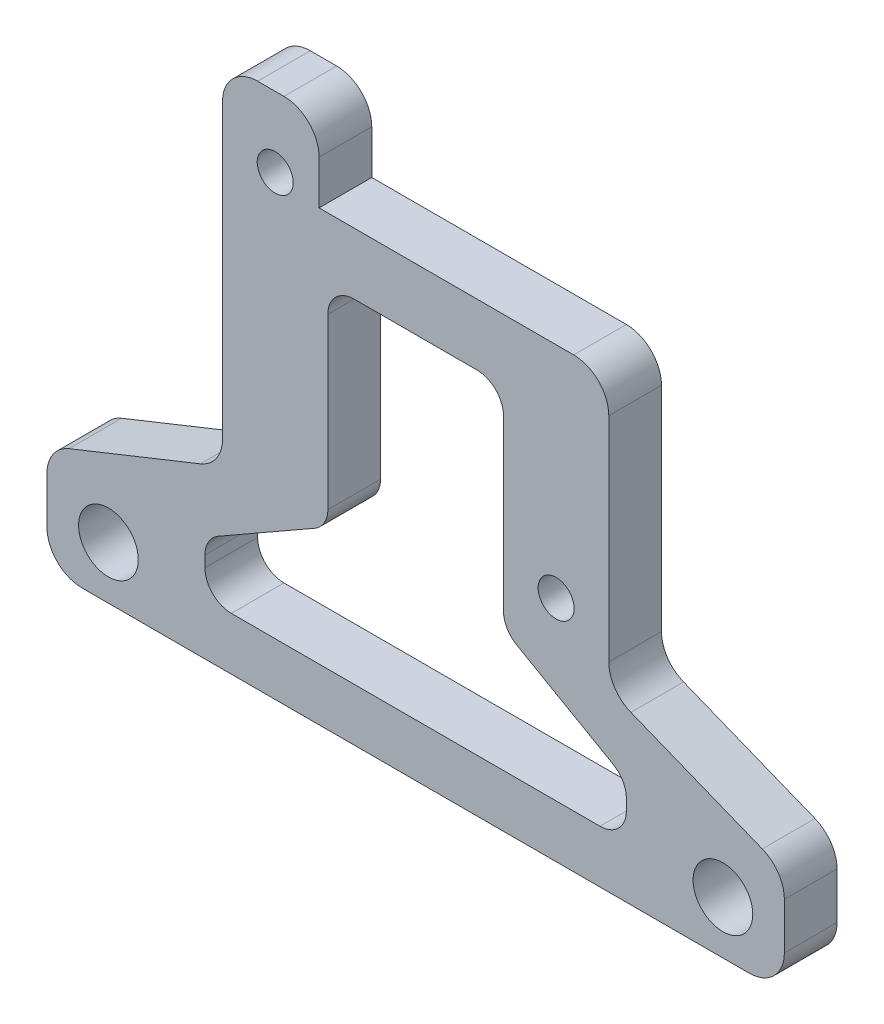
from build123d import *

# Parameters (mm, degrees)
SKETCH1_R                = 0.5
BOSS_EXTRUDE1_DEPTH      = 3
M2_5X0_45_TAPPED_HOLE1_D = 2.05
SKETCH4_W                = 16.5
SKETCH4_H                = 4.5
CUT_EXTRUDE1_DEPTH       = 4
FILLET1_R                = 2
M3_CLEARANCE_HOLE1_D     = 3.4
M3_CLEARANCE_HOLE1_DEPTH = 3
FILLET2_R                = 2


with BuildPart() as part:
    # Sketch1 → Boss-Extrude1 (new body)
    with BuildSketch(Plane.XY):
        Polygon((-21, 0), (21, 0), (21, 6), (11, 10), (11, 30), (-11, 30), (-11, 10), (-21, 6), align=None)
        with Locations((-8, 26)):
            Circle(SKETCH1_R, mode=Mode.SUBTRACT)
        with Locations((8, 13)):
            Circle(SKETCH1_R, mode=Mode.SUBTRACT)
        with Locations((-17.5, 3)):
            Circle(SKETCH1_R, mode=Mode.SUBTRACT)
        with Locations((17.5, 3)):
            Circle(SKETCH1_R, mode=Mode.SUBTRACT)
    extrude(amount=BOSS_EXTRUDE1_DEPTH)

    # M2.5x0.45 Tapped Hole1 (through all)
    with Locations(Plane.XY.offset(3)):
        with Locations((-8, 26), (8, 13)):
            Hole(M2_5X0_45_TAPPED_HOLE1_D / 2)

    # Sketch4 → Cut-Extrude1 (cut, through all)
    with BuildSketch(Plane.XY.offset(3)):
        with Locations((2.75, 27.75)):
            Rectangle(SKETCH4_W, SKETCH4_H)
        with BuildLine():
            Line((-3.5, 22), (3.5, 22))
            ThreePointArc((3.5, 22), (4.560660172, 21.560660172), (5, 20.5))
            Line((5, 20.5), (5, 10.870483803))
            ThreePointArc((5, 10.870483803), (5.20263486, 10.117593576), (5.755791592, 9.56811909))
            Line((5.755791592, 9.56811909), (11.244208408, 6.43188091))
            ThreePointArc((11.244208408, 6.43188091), (11.79736514, 5.882406424), (12, 5.129516197))
            Line((12, 5.129516197), (12, 4.5))
            ThreePointArc((12, 4.5), (11.560660172, 3.439339828), (10.5, 3))
            Line((10.5, 3), (-10.5, 3))
            ThreePointArc((-10.5, 3), (-11.560660172, 3.439339828), (-12, 4.5))
            Line((-12, 4.5), (-12, 5.129516197))
            ThreePointArc((-12, 5.129516197), (-11.79736514, 5.882406424), (-11.244208408, 6.43188091))
            Line((-11.244208408, 6.43188091), (-5.755791592, 9.56811909))
            ThreePointArc((-5.755791592, 9.56811909), (-5.20263486, 10.117593576), (-5, 10.870483803))
            Line((-5, 10.870483803), (-5, 20.5))
            ThreePointArc((-5, 20.5), (-4.560660172, 21.560660172), (-3.5, 22))
        make_face()
    extrude(amount=-CUT_EXTRUDE1_DEPTH, mode=Mode.SUBTRACT)

    # Fillet1
    fillet1_edges = [part.edges().sort_by_distance(p)[0] for p in [
        (-21, 6, 1.5),
        (-11, 10, 1.5),
        (-11, 30, 1.5),
        (11, 10, 1.5),
        (21, 6, 1.5),
        (-5.5, 30, 1.5),
        (11, 25.5, 1.5),
    ]]
    fillet(fillet1_edges, radius=FILLET1_R)

    # M3 Clearance Hole1
    with Locations(Plane.XY.offset(3)):
        with Locations((-17.5, 3), (17.5, 3)):
            Hole(M3_CLEARANCE_HOLE1_D / 2, depth=M3_CLEARANCE_HOLE1_DEPTH)

    # Fillet2
    fillet2_edges = [part.edges().sort_by_distance(p)[0] for p in [
        (21, 0, 1.5),
        (-21, 0, 1.5),
    ]]
    fillet(fillet2_edges, radius=FILLET2_R)


solid = part.part
